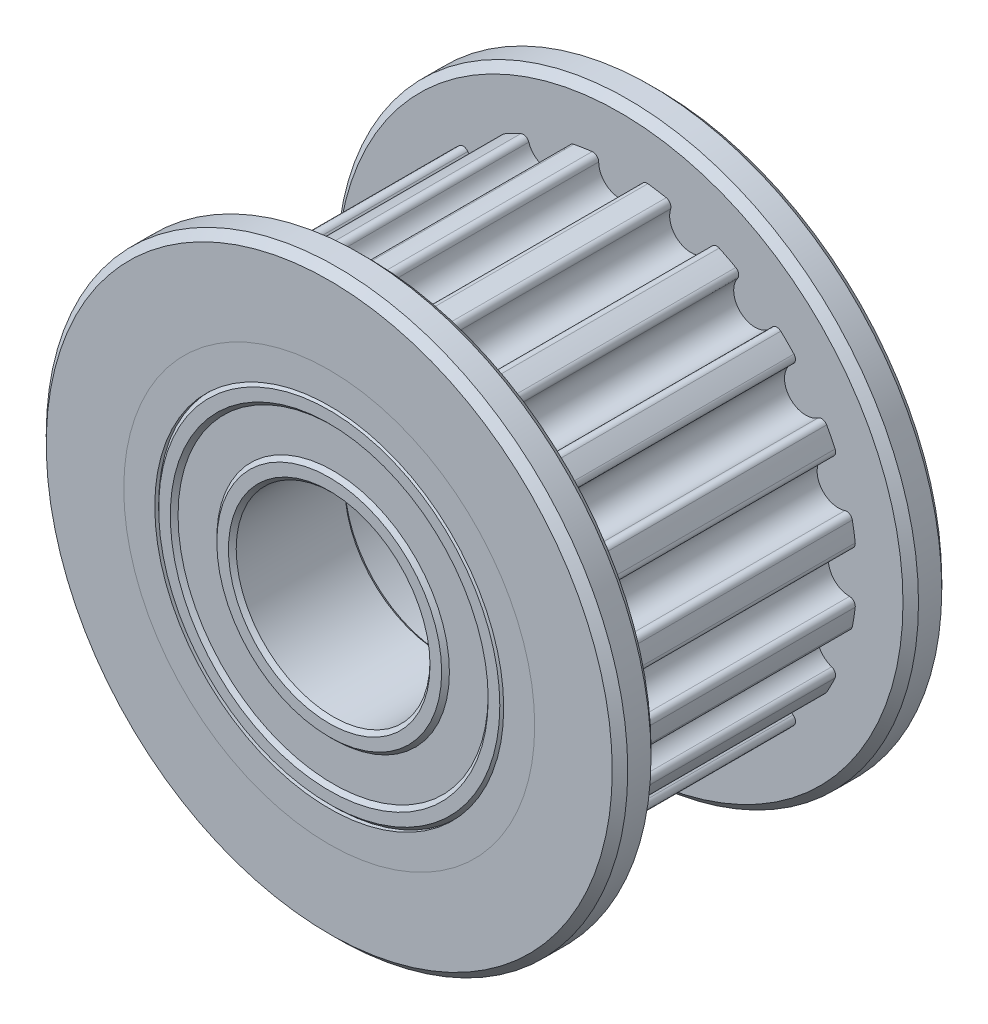
from build123d import *

# Parameters (mm, degrees)
SKICA1_R                  = 5.3
SKICA1_R_2                = 4
P_IDAT_VYSUNUT_M1_DEPTH   = 8.5
SKICA1_3_R                = 7.5
SKICA1_3_R_2              = 5.3
P_IDAT_VYSUNUT_M2_DEPTH   = 1
SKICA2_R                  = 4.75
P_IDAT_VYSUNUT_M5_DEPTH   = 6.5
SKICA4_R                  = 7.5
SKICA4_R_2                = 5.3
P_IDAT_VYSUNUT_M6_DEPTH   = 1
SKICA5_R                  = 4.5
ODEBRAT_VYSUNUT_M3_DEPTH  = 3
ODEBRAT_START             = -3
SKICA6_R                  = 4.5
ODEBRAT_VYSUNUT_M4_DEPTH  = 3
ZKOSEN_1_SIZE             = 0.2
ZKOSEN_2_SIZE             = 0.2
SKICA7_R                  = 4.5
SKICA7_R_2                = 4
P_IDAT_VYSUNUT_M7_DEPTH   = 3
SKICA7_R_3                = 3
SKICA7_R_4                = 2.5
P_IDAT_VYSUNUT_M7_2_DEPTH = 3
P_IDAT_START              = 0.1
SKICA7_3_R                = 4
SKICA7_3_R_2              = 3
P_IDAT_VYSUNUT_M8_DEPTH   = 2.8
ZKOSEN_3_SIZE             = 0.1
ZKOSEN_4_SIZE             = 0.1
SKICA8_R                  = 4.5
SKICA8_R_2                = 4
P_IDAT_VYSUNUT_M9_DEPTH   = 3
SKICA8_R_3                = 3
SKICA8_R_4                = 2.5
P_IDAT_VYSUNUT_M9_2_DEPTH = 3
SKICA8_3_R                = 4
SKICA8_3_R_2              = 3
P_IDAT_VYSUNUT_M10_DEPTH  = 2.8
ZKOSEN_5_SIZE             = 0.1
ZKOSEN_6_SIZE             = 0.1
ZKOSEN_7_SIZE             = 0.1
ZKOSEN_8_SIZE             = 0.1
ZKOSEN_10_SIZE            = 0.1
ZKOSEN_12_SIZE            = 0.1


with BuildPart() as part:
    # Skica1 → P_idat vysunut_m1 (new body)
    with BuildSketch(Plane.XY):
        Circle(SKICA1_R)
        Circle(SKICA1_R_2, mode=Mode.SUBTRACT)
    extrude(amount=P_IDAT_VYSUNUT_M1_DEPTH)

    # Skica5 → Odebrat vysunut_m3 (cut)
    with BuildSketch(Plane.XY.offset(8.5)):
        Circle(SKICA5_R)
    extrude(amount=-ODEBRAT_VYSUNUT_M3_DEPTH, mode=Mode.SUBTRACT)

    # Skica6 → Odebrat vysunut_m4 (cut)
    with BuildSketch(Plane(origin=(0, 0, 0), x_dir=(-1, 0, 0), z_dir=(0, 0, -1)).offset(ODEBRAT_START)):
        Circle(SKICA6_R)
    extrude(amount=ODEBRAT_VYSUNUT_M4_DEPTH, mode=Mode.SUBTRACT)


with BuildPart() as body_2:
    # Skica1_3 → P_idat vysunut_m2 (new body)
    with BuildSketch(Plane.XY):
        Circle(SKICA1_3_R)
        Circle(SKICA1_3_R_2, mode=Mode.SUBTRACT)
    extrude(amount=P_IDAT_VYSUNUT_M2_DEPTH)

    # Zkosen_1
    zkosen_1_edges = [body_2.edges().sort_by_distance(p)[0] for p in [
        (-7.5, 0, 1),
        (-7.5, 0, 0),
    ]]
    chamfer(zkosen_1_edges, length=ZKOSEN_1_SIZE)


with BuildPart() as body_3:
    # Skica2 → P_idat vysunut_m5 (new body)
    with BuildSketch(Plane.XY.offset(1)):
        with BuildLine():
            ThreePointArc((-5.920091772, -0.549978099), (-5.375, 0), (-5.920091772, 0.549978099))
            ThreePointArc((-5.920091772, 0.549978099), (-6.031318276, 0.60083033), (-6.067715073, 0.717588874))
            ThreePointArc((-6.067715073, 0.717588874), (-6.034775761, 0.955814581), (-5.992487116, 1.1925595))
            ThreePointArc((-5.992487116, 1.1925595), (-5.921791331, 1.292356245), (-5.800294436, 1.306348711))
            ThreePointArc((-5.800294436, 1.306348711), (-5.111928775, 1.660966345), (-5.460389278, 2.352469221))
            ThreePointArc((-5.460389278, 2.352469221), (-5.550457765, 2.435203446), (-5.548992802, 2.557494649))
            ThreePointArc((-5.548992802, 2.557494649), (-5.444049863, 2.773881953), (-5.330672769, 2.985971841))
            ThreePointArc((-5.330672769, 2.985971841), (-5.232598191, 3.059037987), (-5.112723868, 3.034801007))
            ThreePointArc((-5.112723868, 3.034801007), (-4.348466345, 3.159345731), (-4.466185836, 3.924684264))
            ThreePointArc((-4.466185836, 3.924684264), (-4.526279777, 4.031201882), (-4.487096454, 4.147055029))
            ThreePointArc((-4.487096454, 4.147055029), (-4.320422433, 4.320422433), (-4.147055029, 4.487096454))
            ThreePointArc((-4.147055029, 4.487096454), (-4.031201882, 4.526279777), (-3.924684264, 4.466185836))
            ThreePointArc((-3.924684264, 4.466185836), (-3.159345731, 4.348466345), (-3.034801007, 5.112723868))
            ThreePointArc((-3.034801007, 5.112723868), (-3.059037987, 5.232598191), (-2.985971841, 5.330672769))
            ThreePointArc((-2.985971841, 5.330672769), (-2.773881953, 5.444049863), (-2.557494649, 5.548992802))
            ThreePointArc((-2.557494649, 5.548992802), (-2.435203446, 5.550457765), (-2.352469221, 5.460389278))
            ThreePointArc((-2.352469221, 5.460389278), (-1.660966345, 5.111928775), (-1.306348711, 5.800294436))
            ThreePointArc((-1.306348711, 5.800294436), (-1.292356245, 5.921791331), (-1.1925595, 5.992487116))
            ThreePointArc((-1.1925595, 5.992487116), (-0.955814581, 6.034775761), (-0.717588874, 6.067715073))
            ThreePointArc((-0.717588874, 6.067715073), (-0.60083033, 6.031318276), (-0.549978099, 5.920091772))
            ThreePointArc((-0.549978099, 5.920091772), (0, 5.375), (0.549978099, 5.920091772))
            ThreePointArc((0.549978099, 5.920091772), (0.60083033, 6.031318276), (0.717588874, 6.067715073))
            ThreePointArc((0.717588874, 6.067715073), (0.955814581, 6.034775761), (1.1925595, 5.992487116))
            ThreePointArc((1.1925595, 5.992487116), (1.292356245, 5.921791331), (1.306348711, 5.800294436))
            ThreePointArc((1.306348711, 5.800294436), (1.660966345, 5.111928775), (2.352469221, 5.460389278))
            ThreePointArc((2.352469221, 5.460389278), (2.435203446, 5.550457765), (2.557494649, 5.548992802))
            ThreePointArc((2.557494649, 5.548992802), (2.773881953, 5.444049863), (2.985971841, 5.330672769))
            ThreePointArc((2.985971841, 5.330672769), (3.059037987, 5.232598191), (3.034801007, 5.112723868))
            ThreePointArc((3.034801007, 5.112723868), (3.159345731, 4.348466345), (3.924684264, 4.466185836))
            ThreePointArc((3.924684264, 4.466185836), (4.031201882, 4.526279777), (4.147055029, 4.487096454))
            ThreePointArc((4.147055029, 4.487096454), (4.320422433, 4.320422433), (4.487096454, 4.147055029))
            ThreePointArc((4.487096454, 4.147055029), (4.526279777, 4.031201882), (4.466185836, 3.924684264))
            ThreePointArc((4.466185836, 3.924684264), (4.348466345, 3.159345731), (5.112723868, 3.034801007))
            ThreePointArc((5.112723868, 3.034801007), (5.232598191, 3.059037987), (5.330672769, 2.985971841))
            ThreePointArc((5.330672769, 2.985971841), (5.444049863, 2.773881953), (5.548992802, 2.557494649))
            ThreePointArc((5.548992802, 2.557494649), (5.550457765, 2.435203446), (5.460389278, 2.352469221))
            ThreePointArc((5.460389278, 2.352469221), (5.111928775, 1.660966345), (5.800294436, 1.306348711))
            ThreePointArc((5.800294436, 1.306348711), (5.921791331, 1.292356245), (5.992487116, 1.1925595))
            ThreePointArc((5.992487116, 1.1925595), (6.034775761, 0.955814581), (6.067715073, 0.717588874))
            ThreePointArc((6.067715073, 0.717588874), (6.031318276, 0.60083033), (5.920091772, 0.549978099))
            ThreePointArc((5.920091772, 0.549978099), (5.375, 0), (5.920091772, -0.549978099))
            ThreePointArc((5.920091772, -0.549978099), (6.031318276, -0.60083033), (6.067715073, -0.717588874))
            ThreePointArc((6.067715073, -0.717588874), (6.034775761, -0.955814581), (5.992487116, -1.1925595))
            ThreePointArc((5.992487116, -1.1925595), (5.921791331, -1.292356245), (5.800294436, -1.306348711))
            ThreePointArc((5.800294436, -1.306348711), (5.111928775, -1.660966345), (5.460389278, -2.352469221))
            ThreePointArc((5.460389278, -2.352469221), (5.550457765, -2.435203446), (5.548992802, -2.557494649))
            ThreePointArc((5.548992802, -2.557494649), (5.444049863, -2.773881953), (5.330672769, -2.985971841))
            ThreePointArc((5.330672769, -2.985971841), (5.232598191, -3.059037987), (5.112723868, -3.034801007))
            ThreePointArc((5.112723868, -3.034801007), (4.348466345, -3.159345731), (4.466185836, -3.924684264))
            ThreePointArc((4.466185836, -3.924684264), (4.526279777, -4.031201882), (4.487096454, -4.147055029))
            ThreePointArc((4.487096454, -4.147055029), (4.320422433, -4.320422433), (4.147055029, -4.487096454))
            ThreePointArc((4.147055029, -4.487096454), (4.031201882, -4.526279777), (3.924684264, -4.466185836))
            ThreePointArc((3.924684264, -4.466185836), (3.159345731, -4.348466345), (3.034801007, -5.112723868))
            ThreePointArc((3.034801007, -5.112723868), (3.059037987, -5.232598191), (2.985971841, -5.330672769))
            ThreePointArc((2.985971841, -5.330672769), (2.773881953, -5.444049863), (2.557494649, -5.548992802))
            ThreePointArc((2.557494649, -5.548992802), (2.435203446, -5.550457765), (2.352469221, -5.460389278))
            ThreePointArc((2.352469221, -5.460389278), (1.660966345, -5.111928775), (1.306348711, -5.800294436))
            ThreePointArc((1.306348711, -5.800294436), (1.292356245, -5.921791331), (1.1925595, -5.992487116))
            ThreePointArc((1.1925595, -5.992487116), (0.955814581, -6.034775761), (0.717588874, -6.067715073))
            ThreePointArc((0.717588874, -6.067715073), (0.60083033, -6.031318276), (0.549978099, -5.920091772))
            ThreePointArc((0.549978099, -5.920091772), (0, -5.375), (-0.549978099, -5.920091772))
            ThreePointArc((-0.549978099, -5.920091772), (-0.60083033, -6.031318276), (-0.717588874, -6.067715073))
            ThreePointArc((-0.717588874, -6.067715073), (-0.955814581, -6.034775761), (-1.1925595, -5.992487116))
            ThreePointArc((-1.1925595, -5.992487116), (-1.292356245, -5.921791331), (-1.306348711, -5.800294436))
            ThreePointArc((-1.306348711, -5.800294436), (-1.660966345, -5.111928775), (-2.352469221, -5.460389278))
            ThreePointArc((-2.352469221, -5.460389278), (-2.435203446, -5.550457765), (-2.557494649, -5.548992802))
            ThreePointArc((-2.557494649, -5.548992802), (-2.773881953, -5.444049863), (-2.985971841, -5.330672769))
            ThreePointArc((-2.985971841, -5.330672769), (-3.059037987, -5.232598191), (-3.034801007, -5.112723868))
            ThreePointArc((-3.034801007, -5.112723868), (-3.159345731, -4.348466345), (-3.924684264, -4.466185836))
            ThreePointArc((-3.924684264, -4.466185836), (-4.031201882, -4.526279777), (-4.147055029, -4.487096454))
            ThreePointArc((-4.147055029, -4.487096454), (-4.320422433, -4.320422433), (-4.487096454, -4.147055029))
            ThreePointArc((-4.487096454, -4.147055029), (-4.526279777, -4.031201882), (-4.466185836, -3.924684264))
            ThreePointArc((-4.466185836, -3.924684264), (-4.348466345, -3.159345731), (-5.112723868, -3.034801007))
            ThreePointArc((-5.112723868, -3.034801007), (-5.232598191, -3.059037987), (-5.330672769, -2.985971841))
            ThreePointArc((-5.330672769, -2.985971841), (-5.444049863, -2.773881953), (-5.548992802, -2.557494649))
            ThreePointArc((-5.548992802, -2.557494649), (-5.550457765, -2.435203446), (-5.460389278, -2.352469221))
            ThreePointArc((-5.460389278, -2.352469221), (-5.111928775, -1.660966345), (-5.800294436, -1.306348711))
            ThreePointArc((-5.800294436, -1.306348711), (-5.921791331, -1.292356245), (-5.992487116, -1.1925595))
            ThreePointArc((-5.992487116, -1.1925595), (-6.034775761, -0.955814581), (-6.067715073, -0.717588874))
            ThreePointArc((-6.067715073, -0.717588874), (-6.031318276, -0.60083033), (-5.920091772, -0.549978099))
        make_face()
        Circle(SKICA2_R, mode=Mode.SUBTRACT)
    extrude(amount=P_IDAT_VYSUNUT_M5_DEPTH)


with BuildPart() as body_4:
    # Skica4 → P_idat vysunut_m6 (new body)
    with BuildSketch(Plane.XY.offset(7.5)):
        Circle(SKICA4_R)
        Circle(SKICA4_R_2, mode=Mode.SUBTRACT)
    extrude(amount=P_IDAT_VYSUNUT_M6_DEPTH)

    # Zkosen_2
    zkosen_2_edges = [body_4.edges().sort_by_distance(p)[0] for p in [
        (-7.5, 0, 7.5),
        (-7.5, 0, 8.5),
    ]]
    chamfer(zkosen_2_edges, length=ZKOSEN_2_SIZE)


with BuildPart() as body_5:
    # Skica7 → P_idat vysunut_m7 (new body)
    with BuildSketch(Plane(origin=(0, 0, 3), x_dir=(-1, 0, 0), z_dir=(0, 0, -1))):
        Circle(SKICA7_R)
        Circle(SKICA7_R_2, mode=Mode.SUBTRACT)
    extrude(amount=P_IDAT_VYSUNUT_M7_DEPTH)

    # Zkosen_3
    zkosen_3_edges = [body_5.edges().sort_by_distance(p)[0] for p in [
        (4, 0, 0),
        (4.5, 0, 0),
    ]]
    chamfer(zkosen_3_edges, length=ZKOSEN_3_SIZE)

    # Zkosen_12
    zkosen_12_edges = [body_5.edges().sort_by_distance(p)[0] for p in [
        (4, 0, 3),
        (4.5, 0, 3),
    ]]
    chamfer(zkosen_12_edges, length=ZKOSEN_12_SIZE)


with BuildPart() as body_6:
    # Skica7 → P_idat vysunut_m7 2 (new body)
    with BuildSketch(Plane(origin=(0, 0, 3), x_dir=(-1, 0, 0), z_dir=(0, 0, -1))):
        Circle(SKICA7_R_3)
        Circle(SKICA7_R_4, mode=Mode.SUBTRACT)
    extrude(amount=P_IDAT_VYSUNUT_M7_2_DEPTH)

    # Zkosen_4
    zkosen_4_edges = [body_6.edges().sort_by_distance(p)[0] for p in [
        (3, 0, 0),
        (2.5, 0, 0),
    ]]
    chamfer(zkosen_4_edges, length=ZKOSEN_4_SIZE)

    # Zkosen_10
    zkosen_10_edges = [body_6.edges().sort_by_distance(p)[0] for p in [
        (3, 0, 3),
        (2.5, 0, 3),
    ]]
    chamfer(zkosen_10_edges, length=ZKOSEN_10_SIZE)


with BuildPart() as body_7:
    # Skica7_3 → P_idat vysunut_m8 (new body)
    with BuildSketch(Plane(origin=(0, 0, 3), x_dir=(-1, 0, 0), z_dir=(0, 0, -1)).offset(P_IDAT_START)):
        Circle(SKICA7_3_R)
        Circle(SKICA7_3_R_2, mode=Mode.SUBTRACT)
    extrude(amount=P_IDAT_VYSUNUT_M8_DEPTH)


with BuildPart() as body_8:
    # Skica8 → P_idat vysunut_m9 (new body)
    with BuildSketch(Plane.XY.offset(5.5)):
        Circle(SKICA8_R)
        Circle(SKICA8_R_2, mode=Mode.SUBTRACT)
    extrude(amount=P_IDAT_VYSUNUT_M9_DEPTH)

    # Zkosen_5
    zkosen_5_edges = [body_8.edges().sort_by_distance(p)[0] for p in [
        (-4, 0, 8.5),
        (-4.5, 0, 8.5),
    ]]
    chamfer(zkosen_5_edges, length=ZKOSEN_5_SIZE)

    # Zkosen_8
    zkosen_8_edges = [body_8.edges().sort_by_distance(p)[0] for p in [
        (-4.5, 0, 5.5),
        (-4, 0, 5.5),
    ]]
    chamfer(zkosen_8_edges, length=ZKOSEN_8_SIZE)


with BuildPart() as body_9:
    # Skica8 → P_idat vysunut_m9 2 (new body)
    with BuildSketch(Plane.XY.offset(5.5)):
        Circle(SKICA8_R_3)
        Circle(SKICA8_R_4, mode=Mode.SUBTRACT)
    extrude(amount=P_IDAT_VYSUNUT_M9_2_DEPTH)

    # Zkosen_6
    zkosen_6_edges = [body_9.edges().sort_by_distance(p)[0] for p in [
        (-3, 0, 8.5),
        (-2.5, 0, 8.5),
    ]]
    chamfer(zkosen_6_edges, length=ZKOSEN_6_SIZE)

    # Zkosen_7
    zkosen_7_edges = [body_9.edges().sort_by_distance(p)[0] for p in [
        (-3, 0, 5.5),
        (-2.5, 0, 5.5),
    ]]
    chamfer(zkosen_7_edges, length=ZKOSEN_7_SIZE)


with BuildPart() as body_10:
    # Skica8_3 → P_idat vysunut_m10 (new body)
    with BuildSketch(Plane.XY.offset(5.5).offset(P_IDAT_START)):
        Circle(SKICA8_3_R)
        Circle(SKICA8_3_R_2, mode=Mode.SUBTRACT)
    extrude(amount=P_IDAT_VYSUNUT_M10_DEPTH)


solid = Compound([part.part, body_2.part, body_3.part, body_4.part, body_5.part, body_6.part, body_7.part, body_8.part, body_9.part, body_10.part])
